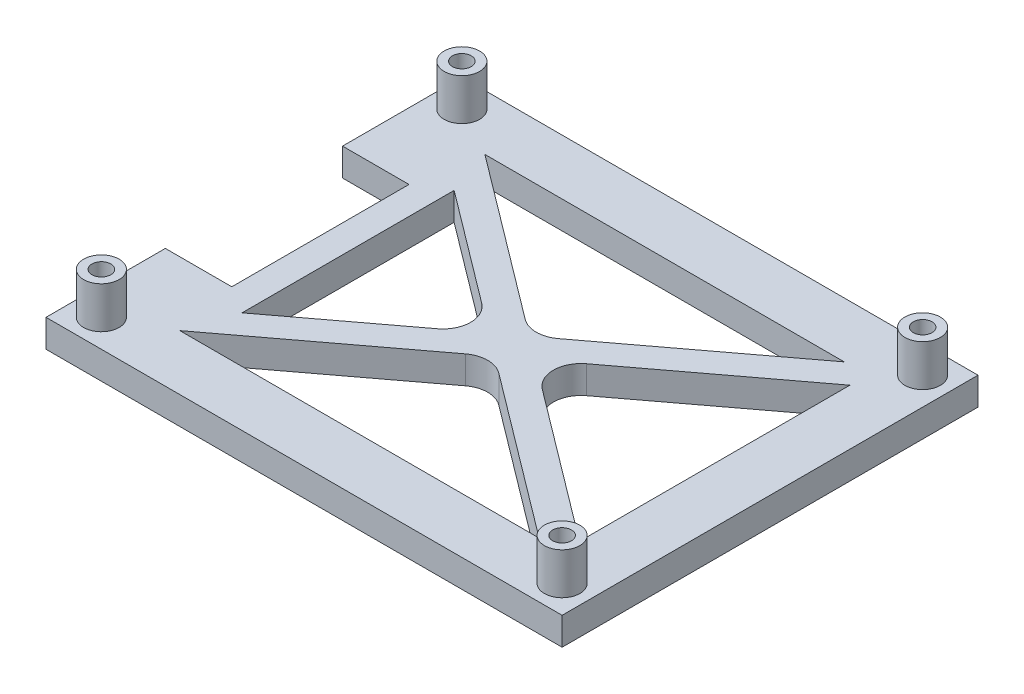
from build123d import *

# Parameters (mm, degrees)
SKETCH2_W           = 93.2
SKETCH2_H           = 75.1
SKETCH2_R           = 1.7
BOSS_EXTRUDE2_DEPTH = 5
FILLET1_R           = 5
SKETCH4_R           = 3.2
SKETCH4_R_2         = 1.7
BOSS_EXTRUDE3_DEPTH = 7.5
SKETCH6_W           = 10
SKETCH6_H           = 32
CUT_EXTRUDE1_DEPTH  = 6
BOSS_EXTRUDE4_DEPTH = 5


with BuildPart() as part:
    # Sketch2 → Boss-Extrude2 (new body)
    with BuildSketch(Plane(origin=(0, 0, 0), x_dir=(1, 0, 0), z_dir=(0, 1, 0))):
        Rectangle(SKETCH2_W, SKETCH2_H)
        with Locations((-41.6, 32.55)):
            Circle(SKETCH2_R, mode=Mode.SUBTRACT)
        with Locations((41.6, 32.55)):
            Circle(SKETCH2_R, mode=Mode.SUBTRACT)
        with Locations((41.6, -32.55)):
            Circle(SKETCH2_R, mode=Mode.SUBTRACT)
        with Locations((-41.6, -32.55)):
            Circle(SKETCH2_R, mode=Mode.SUBTRACT)
        Polygon((-36.6, -24.420896868), (-36.6, 24.420896868), (-4.156993635, 0), align=None, mode=Mode.SUBTRACT)
        Polygon((36.6, -24.420896868), (36.6, 24.420896868), (4.156993635, 0), align=None, mode=Mode.SUBTRACT)
        Polygon((32.443006365, -27.55), (-32.443006365, -27.55), (0, -3.129103132), align=None, mode=Mode.SUBTRACT)
        Polygon((-32.443006365, 27.55), (0, 3.129103132), (32.443006365, 27.55), align=None, mode=Mode.SUBTRACT)
    extrude(amount=BOSS_EXTRUDE2_DEPTH)

    # Fillet1
    fillet1_edges = [part.edges().sort_by_distance(p)[0] for p in [
        (0, 2.5, 3.129103132),
        (-4.156993635, 2.5, 0),
        (4.156993635, 2.5, 0),
        (0, 2.5, -3.129103132),
    ]]
    fillet(fillet1_edges, radius=FILLET1_R)

    # Sketch4 → Boss-Extrude3 (add)
    with BuildSketch(Plane(origin=(0, 5, 0), x_dir=(1, 0, 0), z_dir=(0, 1, 0))):
        with Locations((-41.6, 32.55)):
            Circle(SKETCH4_R)
        with Locations((-41.6, 32.55)):
            Circle(SKETCH4_R_2, mode=Mode.SUBTRACT)
        with Locations((41.6, 32.55)):
            Circle(SKETCH4_R)
        with Locations((41.6, 32.55)):
            Circle(SKETCH4_R_2, mode=Mode.SUBTRACT)
        with Locations((-41.6, -32.55)):
            Circle(SKETCH4_R)
        with Locations((-41.6, -32.55)):
            Circle(SKETCH4_R_2, mode=Mode.SUBTRACT)
        with Locations((41.6, -32.55)):
            Circle(SKETCH4_R)
        with Locations((41.6, -32.55)):
            Circle(SKETCH4_R_2, mode=Mode.SUBTRACT)
    extrude(amount=BOSS_EXTRUDE3_DEPTH)

    # Sketch6 → Cut-Extrude1 (cut, through all)
    with BuildSketch(Plane(origin=(0, 5, 0), x_dir=(1, 0, 0), z_dir=(0, 1, 0))):
        with Locations((-41.6, 0)):
            Rectangle(SKETCH6_W, SKETCH6_H)
    extrude(amount=-CUT_EXTRUDE1_DEPTH, mode=Mode.SUBTRACT)

    # Sketch7 → Boss-Extrude4 (add)
    with BuildSketch(Plane(origin=(0, 5, 0), x_dir=(1, 0, 0), z_dir=(0, 1, 0))):
        Polygon((-36.6, 16), (-34.6, 16), (-34.6, -16), (-36.6, -16), (-36.6, -24.420896868), (-29.6, -19.151771185), (-29.6, 19.151771185), (-36.6, 24.420896868), align=None)
    extrude(amount=-BOSS_EXTRUDE4_DEPTH)


solid = part.part
